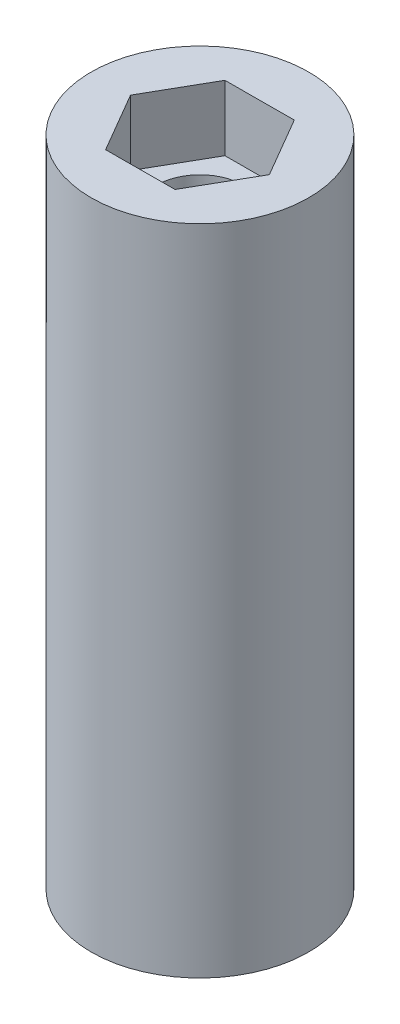
from build123d import *

# Parameters (mm, degrees)
SKETCH1_R           = 5
BOSS_EXTRUDE1_DEPTH = 30
SKETCH2_R           = 2
CUT_EXTRUDE1_DEPTH  = 31
CUT_EXTRUDE2_DEPTH  = 3
LPATTERN1_COUNT     = 2
LPATTERN1_PITCH     = 27


with BuildPart() as part:
    # Sketch1 → Boss-Extrude1 (new body)
    with BuildSketch(Plane(origin=(0, 0, 0), x_dir=(1, 0, 0), z_dir=(0, 1, 0))):
        Circle(SKETCH1_R)
    extrude(amount=BOSS_EXTRUDE1_DEPTH)

    # Sketch2 → Cut-Extrude1 (cut, through all)
    with BuildSketch(Plane(origin=(0, 30, 0), x_dir=(1, 0, 0), z_dir=(0, 1, 0))):
        Circle(SKETCH2_R)
    extrude(amount=-CUT_EXTRUDE1_DEPTH, mode=Mode.SUBTRACT)

    # Sketch3 → Cut-Extrude2 (cut)
    with BuildSketch(Plane(origin=(0, 30, 0), x_dir=(1, 0, 0), z_dir=(0, 1, 0))):
        Polygon((1.599030575, -2.74343481), (3.175399526, 0.013083694), (1.576368951, 2.756518504), (-1.599030575, 2.74343481), (-3.175399526, -0.013083694), (-1.576368951, -2.756518504), align=None)
    cut_extrude2 = extrude(amount=-CUT_EXTRUDE2_DEPTH, mode=Mode.SUBTRACT)

    # LPattern1: Cut-Extrude2 ×2
    with Locations(*[(0, -i * LPATTERN1_PITCH, 0) for i in range(1, LPATTERN1_COUNT)]):
        add(cut_extrude2, mode=Mode.SUBTRACT)


solid = part.part
